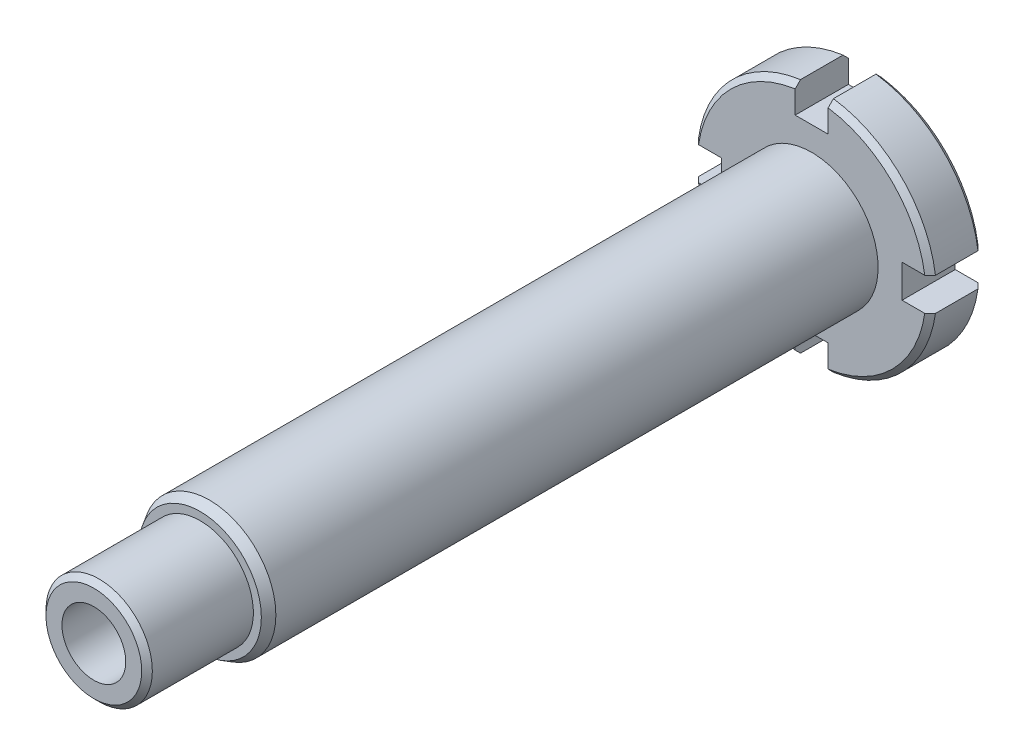
from build123d import *

# Parameters (mm, degrees)
CHANFREIN1_SIZE              = 1
ESQUISSE3_R                  = 6
ENL_V_MAT_EXTRU_2_DEPTH      = 146
ENL_V_MAT_EXTRU_1_DEPTH      = 146
R_P_TITION_CIRCULAIRE1_COUNT = 4
CHANFREIN2_SIZE              = 1
CHANFREIN2_SIZE2             = 1.732050808


with BuildPart() as part:
    # Esquisse1 → Révolution1 (revolve)
    with BuildSketch(Plane(origin=(0, 0, 0), x_dir=(0, 0, -1), z_dir=(1, 0, 0)), mode=Mode.PRIVATE) as r_volution1_sk:
        Polygon((-145, 0), (-145, 10), (-125, 10), (-125, 12.5), (-10, 12.5), (-10, 22.5), (0, 22.5), (0, 0), align=None)
    revolve(r_volution1_sk.sketch.rotate(Axis((0, 0, 0), (0, 0, 1)), 90), axis=Axis((0, 0, 0), (0, 0, 1)))  # turned: the seam where the file's is

    # Chanfrein1
    chanfrein1_edges = [part.edges().sort_by_distance(p)[0] for p in [
        (22.5, 0, 0),
        (22.5, 0, 10),
        (10, 0, 145),
    ]]
    chamfer(chanfrein1_edges, length=CHANFREIN1_SIZE)

    # Esquisse3 → Enlèv. mat.-Extru.2 (cut, through all)
    with BuildSketch(Plane(origin=(0, 0, 0), x_dir=(-1, 0, 0), z_dir=(0, 0, -1))):
        Circle(ESQUISSE3_R)
    extrude(amount=-ENL_V_MAT_EXTRU_2_DEPTH, mode=Mode.SUBTRACT)

    # Esquisse2 → Enlèv. mat.-Extru.1 (cut, through all)
    with BuildSketch(Plane(origin=(0, 0, 0), x_dir=(-1, 0, 0), z_dir=(0, 0, -1))):
        with BuildLine():
            Line((-3.1, 22.285421243), (-3.1, 17))
            Line((-3.1, 17), (3.1, 17))
            Line((3.1, 17), (3.1, 22.285421243))
            ThreePointArc((3.1, 22.285421243), (0, 22.5), (-3.1, 22.285421243))
        make_face()
    enl_v_mat_extru_1 = extrude(amount=-ENL_V_MAT_EXTRU_1_DEPTH, mode=Mode.SUBTRACT)

    # Répétition circulaire1: Enlèv. mat.-Extru.1 ×4 about axis
    r_p_tition_circulaire1_axis = Axis((0, 0, 0), (0, 0, 1))
    for i in range(1, R_P_TITION_CIRCULAIRE1_COUNT):
        add(enl_v_mat_extru_1.rotate(r_p_tition_circulaire1_axis, i * 360 / R_P_TITION_CIRCULAIRE1_COUNT), mode=Mode.SUBTRACT)

    # Chanfrein2
    chanfrein2_edges = [part.edges().sort_by_distance(p)[0] for p in [
        (12.5, 0, 125),
    ]]
    chanfrein2_side = [part.faces().sort_by_distance(p)[0] for p in [
        (10.353553391, 0, 125),
    ]]
    chamfer(chanfrein2_edges, length=CHANFREIN2_SIZE, length2=CHANFREIN2_SIZE2, reference=chanfrein2_side[0])


solid = part.part
